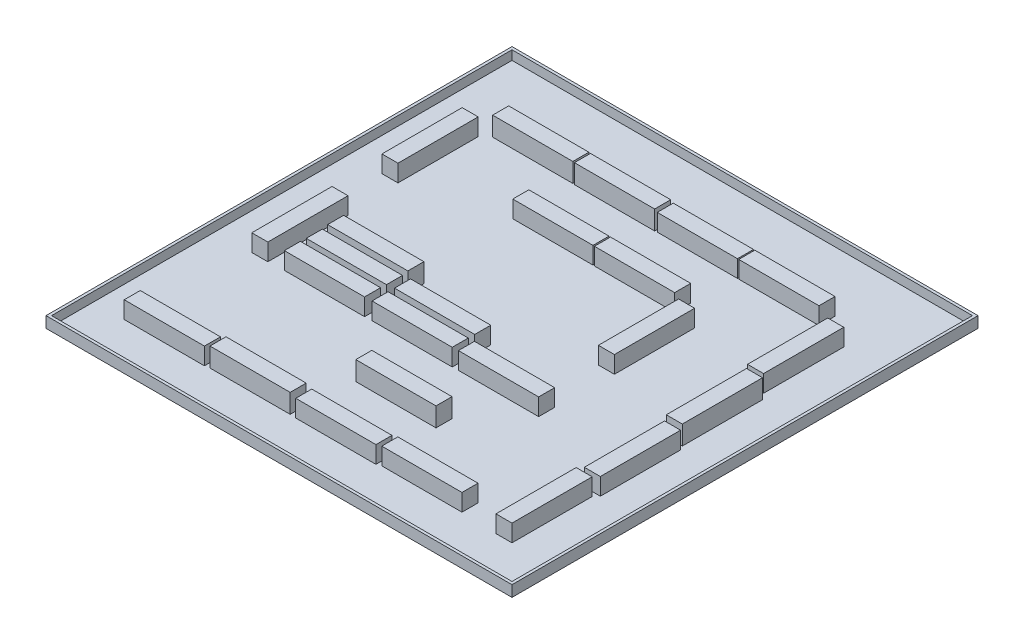
from build123d import *

# Parameters (mm, degrees)
IZIM2_W                      = 5060
IZIM2_H                      = 5060
Y_KSEKLIK_EKSTR_ZYON1_DEPTH  = 20
IZIM3_W                      = 5060
IZIM3_H                      = 5060
IZIM3_W_2                    = 5000
IZIM3_H_2                    = 5000
Y_KSEKLIK_EKSTR_ZYON2_DEPTH  = 100
IZIM4_W                      = 871
IZIM4_H                      = 174
Y_KSEKLIK_EKSTR_ZYON3_DEPTH  = 207
IZIM5_W                      = 871
IZIM5_H                      = 174
Y_KSEKLIK_EKSTR_ZYON4_DEPTH  = 207
IZIM6_W                      = 871
IZIM6_H                      = 174
Y_KSEKLIK_EKSTR_ZYON5_DEPTH  = 185.7
IZIM7_W                      = 871
IZIM7_H                      = 174
Y_KSEKLIK_EKSTR_ZYON6_DEPTH  = 185.7
IZIM8_W                      = 871
IZIM8_H                      = 174
Y_KSEKLIK_EKSTR_ZYON7_DEPTH  = 185.7
IZIM9_W                      = 871
IZIM9_H                      = 174
Y_KSEKLIK_EKSTR_ZYON8_DEPTH  = 185.7
IZIM10_W                     = 871
IZIM10_H                     = 174
Y_KSEKLIK_EKSTR_ZYON9_DEPTH  = 207
IZIM11_W                     = 871
IZIM11_H                     = 174
Y_KSEKLIK_EKSTR_ZYON10_DEPTH = 185.7
IZIM12_W                     = 871
IZIM12_H                     = 174
Y_KSEKLIK_EKSTR_ZYON11_DEPTH = 185.7
IZIM18_W                     = 174
IZIM18_H                     = 871
Y_KSEKLIK_EKSTR_ZYON12_DEPTH = 185.7
IZIM13_W                     = 174
IZIM13_H                     = 871
Y_KSEKLIK_EKSTR_ZYON13_DEPTH = 185.7
IZIM17_W                     = 174
IZIM17_H                     = 871
Y_KSEKLIK_EKSTR_ZYON14_DEPTH = 207
IZIM19_W                     = 174
IZIM19_H                     = 871
Y_KSEKLIK_EKSTR_ZYON15_DEPTH = 185.7
IZIM20_W                     = 174
IZIM20_H                     = 871
Y_KSEKLIK_EKSTR_ZYON16_DEPTH = 185.7
IZIM21_W                     = 174
IZIM21_H                     = 871
Y_KSEKLIK_EKSTR_ZYON17_DEPTH = 185.7
IZIM22_W                     = 871
IZIM22_H                     = 174
Y_KSEKLIK_EKSTR_ZYON18_DEPTH = 185.7
IZIM23_W                     = 871
IZIM23_H                     = 174
Y_KSEKLIK_EKSTR_ZYON19_DEPTH = 185.7
IZIM24_W                     = 871
IZIM24_H                     = 174
Y_KSEKLIK_EKSTR_ZYON20_DEPTH = 185.7
IZIM25_W                     = 871
IZIM25_H                     = 174
Y_KSEKLIK_EKSTR_ZYON21_DEPTH = 207
IZIM26_W                     = 871
IZIM26_H                     = 174
Y_KSEKLIK_EKSTR_ZYON22_DEPTH = 185.7
IZIM28_W                     = 871
IZIM28_H                     = 174
Y_KSEKLIK_EKSTR_ZYON23_DEPTH = 207
IZIM27_W                     = 871
IZIM27_H                     = 174
Y_KSEKLIK_EKSTR_ZYON24_DEPTH = 185.7
IZIM29_W                     = 871
IZIM29_H                     = 174
Y_KSEKLIK_EKSTR_ZYON25_DEPTH = 185.7
IZIM30_W                     = 174
IZIM30_H                     = 871
Y_KSEKLIK_EKSTR_ZYON26_DEPTH = 185.7


with BuildPart() as part:
    # Çizim2 → Yükseklik-Ekstrüzyon1 (new body)
    with BuildSketch(Plane(origin=(0, 0, 0), x_dir=(1, 0, 0), z_dir=(0, 1, 0))):
        Rectangle(IZIM2_W, IZIM2_H)
    extrude(amount=Y_KSEKLIK_EKSTR_ZYON1_DEPTH)

    # Çizim3 → Yükseklik-Ekstrüzyon2 (add)
    with BuildSketch(Plane(origin=(0, 20, 0), x_dir=(1, 0, 0), z_dir=(0, 1, 0))):
        Rectangle(IZIM3_W, IZIM3_H)
        Rectangle(IZIM3_W_2, IZIM3_H_2, mode=Mode.SUBTRACT)
    extrude(amount=Y_KSEKLIK_EKSTR_ZYON2_DEPTH)

    # Çizim4 → Yükseklik-Ekstrüzyon3 (add)
    with BuildSketch(Plane(origin=(0, 20, 0), x_dir=(1, 0, 0), z_dir=(0, 1, 0))):
        with Locations((-1447.957868124, 1760.193885562)):
            Rectangle(IZIM4_W, IZIM4_H)
    extrude(amount=Y_KSEKLIK_EKSTR_ZYON3_DEPTH)

    # Çizim5 → Yükseklik-Ekstrüzyon4 (add)
    with BuildSketch(Plane(origin=(0, 20, 0), x_dir=(1, 0, 0), z_dir=(0, 1, 0))):
        with Locations((-556.962470649, 1757.302581604)):
            Rectangle(IZIM5_W, IZIM5_H)
    extrude(amount=Y_KSEKLIK_EKSTR_ZYON4_DEPTH)

    # Çizim6 → Yükseklik-Ekstrüzyon5 (add)
    with BuildSketch(Plane(origin=(0, 20, 0), x_dir=(1, 0, 0), z_dir=(0, 1, 0))):
        with Locations((339.047077841, 1760.84910081)):
            Rectangle(IZIM6_W, IZIM6_H)
    extrude(amount=Y_KSEKLIK_EKSTR_ZYON5_DEPTH)

    # Çizim7 → Yükseklik-Ekstrüzyon6 (add)
    with BuildSketch(Plane(origin=(0, 20, 0), x_dir=(1, 0, 0), z_dir=(0, 1, 0))):
        with Locations((-570.903208445, 1101.835490201)):
            Rectangle(IZIM7_W, IZIM7_H)
    extrude(amount=Y_KSEKLIK_EKSTR_ZYON6_DEPTH)

    # Çizim8 → Yükseklik-Ekstrüzyon7 (add)
    with BuildSketch(Plane(origin=(0, 20, 0), x_dir=(1, 0, 0), z_dir=(0, 1, 0))):
        with Locations((316.876659873, 1100.921994771)):
            Rectangle(IZIM8_W, IZIM8_H)
    extrude(amount=Y_KSEKLIK_EKSTR_ZYON7_DEPTH)

    # Çizim9 → Yükseklik-Ekstrüzyon8 (add)
    with BuildSketch(Plane(origin=(0, 20, 0), x_dir=(1, 0, 0), z_dir=(0, 1, 0))):
        with Locations((-375.195016834, -378.049975519)):
            Rectangle(IZIM9_W, IZIM9_H)
    extrude(amount=Y_KSEKLIK_EKSTR_ZYON8_DEPTH)

    # Çizim10 → Yükseklik-Ekstrüzyon9 (add)
    with BuildSketch(Plane(origin=(0, 20, 0), x_dir=(1, 0, 0), z_dir=(0, 1, 0))):
        with Locations((-1314.468607653, -164.926600722)):
            Rectangle(IZIM10_W, IZIM10_H)
    extrude(amount=Y_KSEKLIK_EKSTR_ZYON9_DEPTH)

    # Çizim11 → Yükseklik-Ekstrüzyon10 (add)
    with BuildSketch(Plane(origin=(0, 20, 0), x_dir=(1, 0, 0), z_dir=(0, 1, 0))):
        with Locations((1041.332284797, -1932.969392618)):
            Rectangle(IZIM11_W, IZIM11_H)
    extrude(amount=Y_KSEKLIK_EKSTR_ZYON10_DEPTH)

    # Çizim12 → Yükseklik-Ekstrüzyon11 (add)
    with BuildSketch(Plane(origin=(0, 20, 0), x_dir=(1, 0, 0), z_dir=(0, 1, 0))):
        with Locations((1223.858831325, 1760.916349533)):
            Rectangle(IZIM12_W, IZIM12_H)
    extrude(amount=Y_KSEKLIK_EKSTR_ZYON11_DEPTH)

    # Çizim18 → Yükseklik-Ekstrüzyon12 (add)
    with BuildSketch(Plane(origin=(0, 20, 0), x_dir=(1, 0, 0), z_dir=(0, 1, 0))):
        with Locations((1991.233510758, -683.237447543)):
            Rectangle(IZIM18_W, IZIM18_H)
    extrude(amount=Y_KSEKLIK_EKSTR_ZYON12_DEPTH)

    # Çizim13 → Yükseklik-Ekstrüzyon13 (add)
    with BuildSketch(Plane(origin=(0, 20, 0), x_dir=(1, 0, 0), z_dir=(0, 1, 0))):
        with Locations((1909.211579927, 1170.80509888)):
            Rectangle(IZIM13_W, IZIM13_H)
    extrude(amount=Y_KSEKLIK_EKSTR_ZYON13_DEPTH)

    # Çizim17 → Yükseklik-Ekstrüzyon14 (add)
    with BuildSketch(Plane(origin=(0, 20, 0), x_dir=(1, 0, 0), z_dir=(0, 1, 0))):
        with Locations((1964.13053487, 233.678603717)):
            Rectangle(IZIM17_W, IZIM17_H)
    extrude(amount=Y_KSEKLIK_EKSTR_ZYON14_DEPTH)

    # Çizim19 → Yükseklik-Ekstrüzyon15 (add)
    with BuildSketch(Plane(origin=(0, 20, 0), x_dir=(1, 0, 0), z_dir=(0, 1, 0))):
        with Locations((-2053.844695073, 1164.143387532)):
            Rectangle(IZIM19_W, IZIM19_H)
    extrude(amount=Y_KSEKLIK_EKSTR_ZYON15_DEPTH)

    # Çizim20 → Yükseklik-Ekstrüzyon16 (add)
    with BuildSketch(Plane(origin=(0, 20, 0), x_dir=(1, 0, 0), z_dir=(0, 1, 0))):
        with Locations((920.72498976, 539.769496495)):
            Rectangle(IZIM20_W, IZIM20_H)
    extrude(amount=Y_KSEKLIK_EKSTR_ZYON16_DEPTH)

    # Çizim21 → Yükseklik-Ekstrüzyon17 (add)
    with BuildSketch(Plane(origin=(0, 20, 0), x_dir=(1, 0, 0), z_dir=(0, 1, 0))):
        with Locations((1949.549104769, -1601.346637864)):
            Rectangle(IZIM21_W, IZIM21_H)
    extrude(amount=Y_KSEKLIK_EKSTR_ZYON17_DEPTH)

    # Çizim22 → Yükseklik-Ekstrüzyon18 (add)
    with BuildSketch(Plane(origin=(0, 20, 0), x_dir=(1, 0, 0), z_dir=(0, 1, 0))):
        with Locations((-376.557557317, -620.842933612)):
            Rectangle(IZIM22_W, IZIM22_H)
    extrude(amount=Y_KSEKLIK_EKSTR_ZYON18_DEPTH)

    # Çizim23 → Yükseklik-Ekstrüzyon19 (add)
    with BuildSketch(Plane(origin=(0, 20, 0), x_dir=(1, 0, 0), z_dir=(0, 1, 0))):
        with Locations((-1326.024111416, -623.516452973)):
            Rectangle(IZIM23_W, IZIM23_H)
    extrude(amount=Y_KSEKLIK_EKSTR_ZYON19_DEPTH)

    # Çizim24 → Yükseklik-Ekstrüzyon20 (add)
    with BuildSketch(Plane(origin=(0, 20, 0), x_dir=(1, 0, 0), z_dir=(0, 1, 0))):
        with Locations((-1322.557004683, -388.936544417)):
            Rectangle(IZIM24_W, IZIM24_H)
    extrude(amount=Y_KSEKLIK_EKSTR_ZYON20_DEPTH)

    # Çizim25 → Yükseklik-Ekstrüzyon21 (add)
    with BuildSketch(Plane(origin=(0, 20, 0), x_dir=(1, 0, 0), z_dir=(0, 1, 0))):
        with Locations((107.808561485, -1281.512558826)):
            Rectangle(IZIM25_W, IZIM25_H)
    extrude(amount=Y_KSEKLIK_EKSTR_ZYON21_DEPTH)

    # Çizim26 → Yükseklik-Ekstrüzyon22 (add)
    with BuildSketch(Plane(origin=(0, 20, 0), x_dir=(1, 0, 0), z_dir=(0, 1, 0))):
        with Locations((559.151520406, -618.408042064)):
            Rectangle(IZIM26_W, IZIM26_H)
    extrude(amount=Y_KSEKLIK_EKSTR_ZYON22_DEPTH)

    # Çizim28 → Yükseklik-Ekstrüzyon23 (add)
    with BuildSketch(Plane(origin=(0, 20, 0), x_dir=(1, 0, 0), z_dir=(0, 1, 0))):
        with Locations((-811.388936297, -1945.834521363)):
            Rectangle(IZIM28_W, IZIM28_H)
    extrude(amount=Y_KSEKLIK_EKSTR_ZYON23_DEPTH)

    # Çizim27 → Yükseklik-Ekstrüzyon24 (add)
    with BuildSketch(Plane(origin=(0, 20, 0), x_dir=(1, 0, 0), z_dir=(0, 1, 0))):
        with Locations((124.420483528, -1950.295529657)):
            Rectangle(IZIM27_W, IZIM27_H)
    extrude(amount=Y_KSEKLIK_EKSTR_ZYON24_DEPTH)

    # Çizim29 → Yükseklik-Ekstrüzyon25 (add)
    with BuildSketch(Plane(origin=(0, 20, 0), x_dir=(1, 0, 0), z_dir=(0, 1, 0))):
        with Locations((-1733.240195544, -1954.926684942)):
            Rectangle(IZIM29_W, IZIM29_H)
    extrude(amount=Y_KSEKLIK_EKSTR_ZYON25_DEPTH)

    # Çizim30 → Yükseklik-Ekstrüzyon26 (add)
    with BuildSketch(Plane(origin=(0, 20, 0), x_dir=(1, 0, 0), z_dir=(0, 1, 0))):
        with Locations((-2019.015377363, -283.756951612)):
            Rectangle(IZIM30_W, IZIM30_H)
    extrude(amount=Y_KSEKLIK_EKSTR_ZYON26_DEPTH)


solid = part.part
